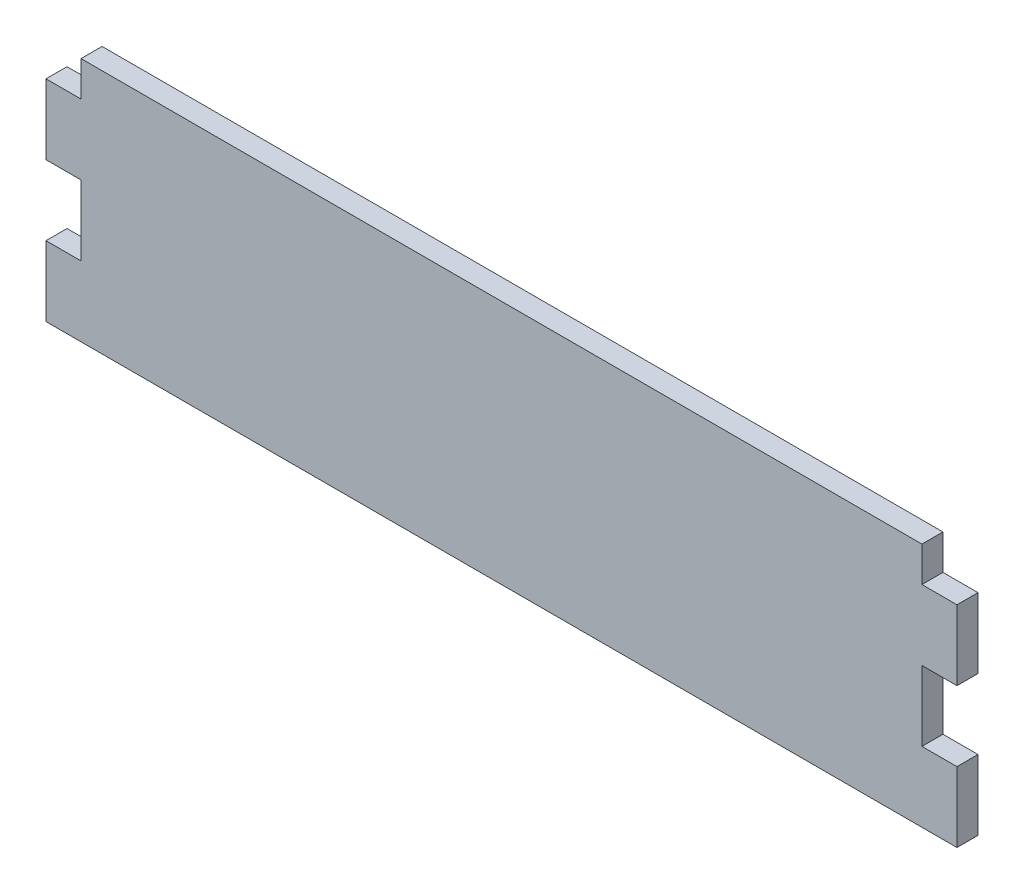
from build123d import *

# Parameters (mm, degrees)
ESQUISSE1_W                = 119.98
ESQUISSE1_H                = 35
BOSS_EXTRU_1_DEPTH         = 3
ESQUISSE2_W                = 3
ESQUISSE2_H                = 10
BOSS_EXTRU_2_DEPTH         = 5
R_P_TITION_LIN_AIRE1_COUNT = 2
R_P_TITION_LIN_AIRE1_PITCH = 20
ESQUISSE3_W                = 3
ESQUISSE3_H                = 10
BOSS_EXTRU_3_DEPTH         = 5
R_P_TITION_LIN_AIRE2_COUNT = 2
R_P_TITION_LIN_AIRE2_PITCH = 20


with BuildPart() as part:
    # Esquisse1 → Boss.-Extru.1 (new body)
    with BuildSketch(Plane.XY):
        with Locations((59.99, -17.5)):
            Rectangle(ESQUISSE1_W, ESQUISSE1_H)
    extrude(amount=BOSS_EXTRU_1_DEPTH)

    # Esquisse2 → Boss.-Extru.2 (add)
    with BuildSketch(Plane.ZY):
        with Locations((1.5, -30)):
            Rectangle(ESQUISSE2_W, ESQUISSE2_H)
    boss_extru_2 = extrude(amount=BOSS_EXTRU_2_DEPTH)

    # Répétition linéaire1: Boss.-Extru.2 ×2
    with Locations(*[(0, i * R_P_TITION_LIN_AIRE1_PITCH, 0) for i in range(1, R_P_TITION_LIN_AIRE1_COUNT)]):
        add(boss_extru_2)

    # Esquisse3 → Boss.-Extru.3 (add)
    with BuildSketch(Plane(origin=(119.98, 0, 0), x_dir=(0, 0, -1), z_dir=(1, 0, 0))):
        with Locations((-1.5, -30)):
            Rectangle(ESQUISSE3_W, ESQUISSE3_H)
    boss_extru_3 = extrude(amount=BOSS_EXTRU_3_DEPTH)

    # Répétition linéaire2: Boss.-Extru.3 ×2
    with Locations(*[(0, i * R_P_TITION_LIN_AIRE2_PITCH, 0) for i in range(1, R_P_TITION_LIN_AIRE2_COUNT)]):
        add(boss_extru_3)


solid = part.part
